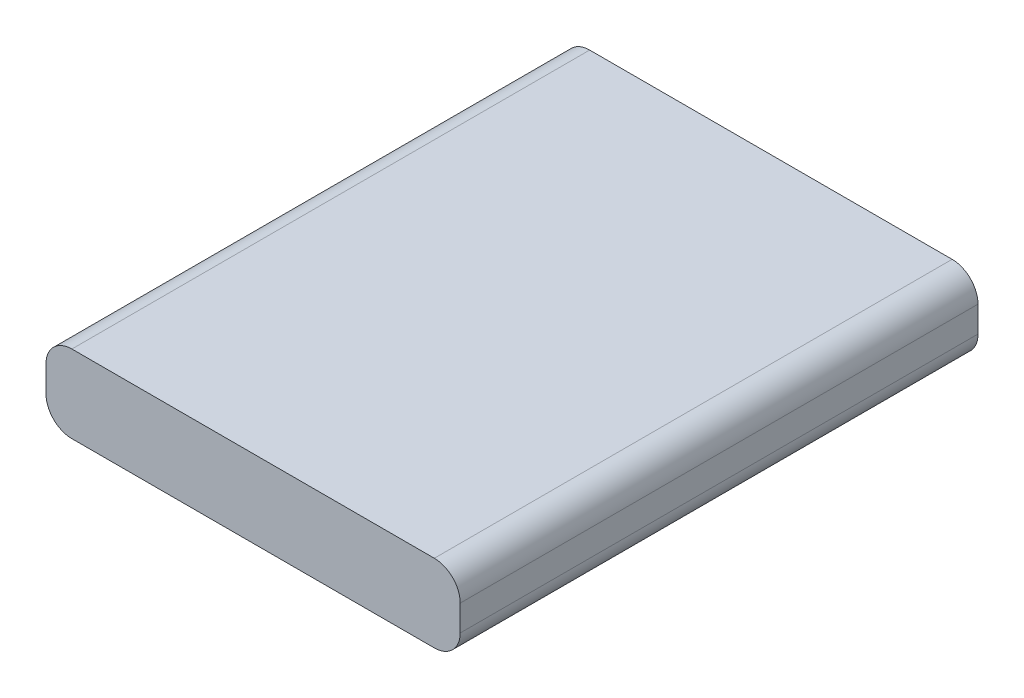
from build123d import *

# Parameters (mm, degrees)
SKETCH1_W           = 48
SKETCH1_H           = 60
BOSS_EXTRUDE1_DEPTH = 9
FILLET1_R           = 3


with BuildPart() as part:
    # Sketch1 → Boss-Extrude1 (new body)
    with BuildSketch(Plane(origin=(0, 0, 0), x_dir=(1, 0, 0), z_dir=(0, 1, 0))):
        Rectangle(SKETCH1_W, SKETCH1_H)
    extrude(amount=BOSS_EXTRUDE1_DEPTH)

    # Fillet1
    fillet1_edges = [part.edges().sort_by_distance(p)[0] for p in [
        (-24, 9, 0),
        (24, 9, 0),
        (-24, 0, 0),
        (24, 0, 0),
    ]]
    fillet(fillet1_edges, radius=FILLET1_R)


solid = part.part
